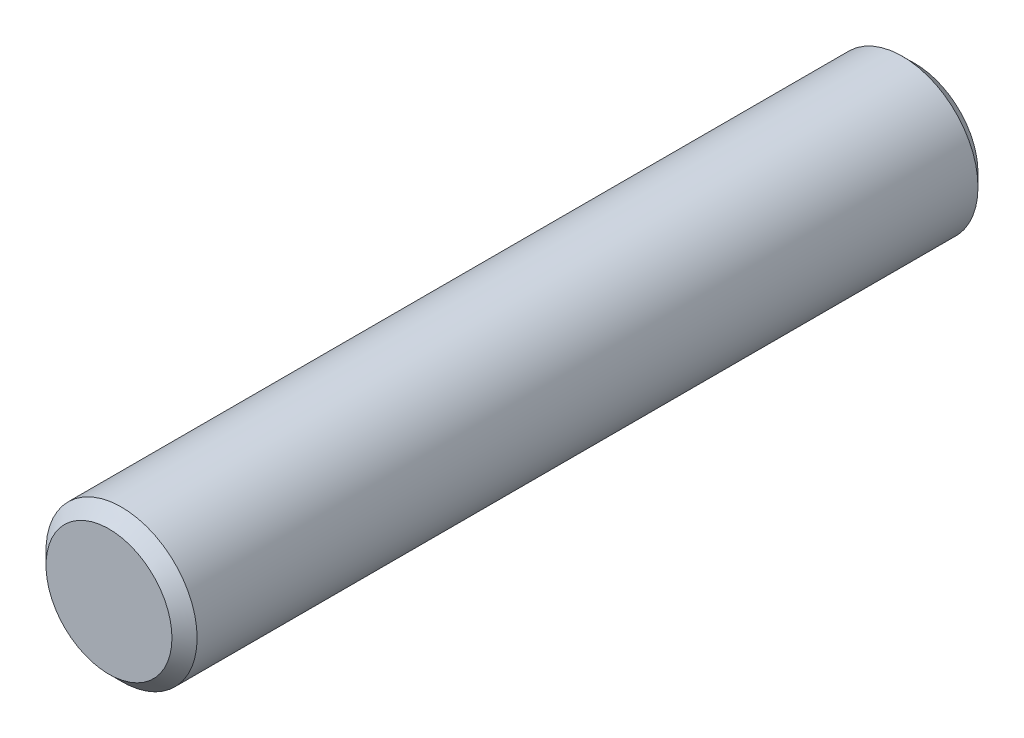
from build123d import *

# Parameters (mm, degrees)
SKETCH_1_R      = 3
EXTRUDE_1_DEPTH = 32
CHAMFER_1_SIZE  = 0.5
CHAMFER_2_SIZE  = 0.5


with BuildPart() as part:
    # 草圖1 → 填料-伸長1 (new body)
    with BuildSketch(Plane.XY):
        Circle(SKETCH_1_R)
    extrude(amount=EXTRUDE_1_DEPTH)

    # 導角1
    chamfer_1_edges = [part.edges().sort_by_distance(p)[0] for p in [
        (-3, 0, 32),
    ]]
    chamfer(chamfer_1_edges, length=CHAMFER_1_SIZE)

    # 導角2
    chamfer_2_edges = [part.edges().sort_by_distance(p)[0] for p in [
        (-3, 0, 0),
    ]]
    chamfer(chamfer_2_edges, length=CHAMFER_2_SIZE)


solid = part.part
